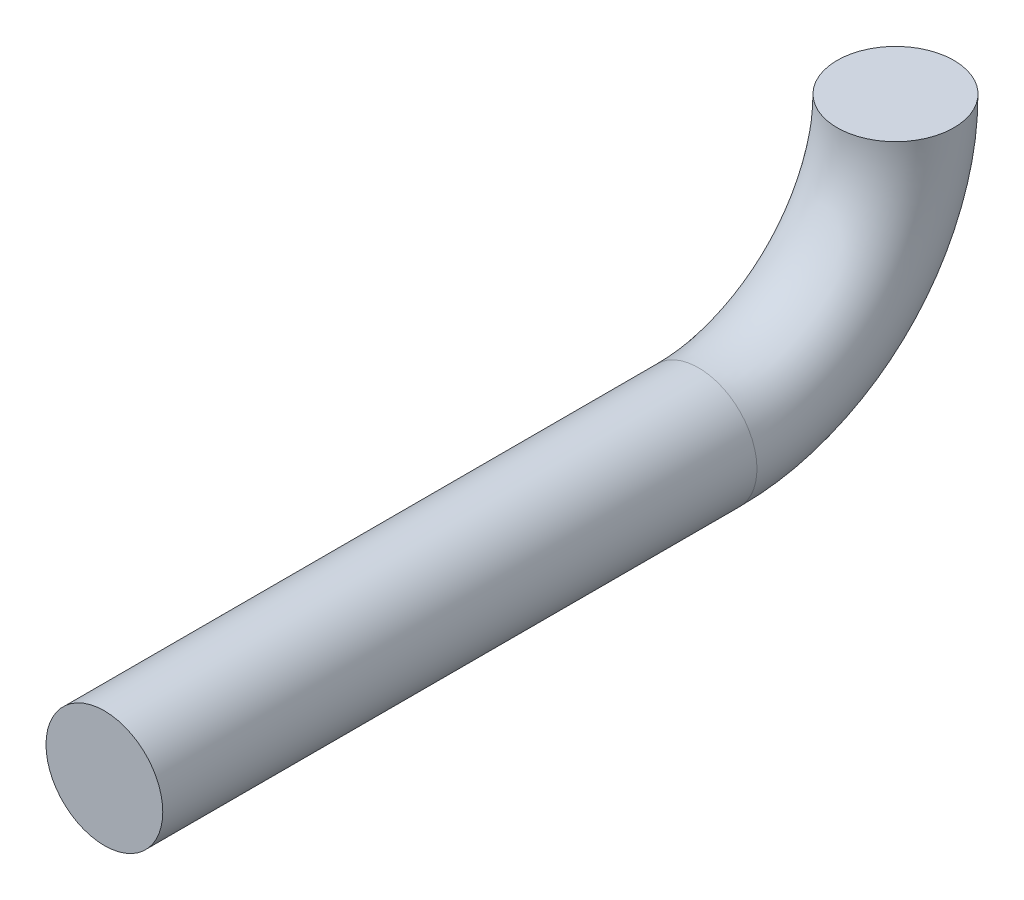
from build123d import *

# Parameters (mm, degrees)
SKETCH2_R = 0.254


with BuildPart() as part:
    # Sweep1: sweep along a path in Sketch1
    with BuildLine(Plane(origin=(0, 0, 0), x_dir=(0, 0, -1), z_dir=(1, 0, 0))) as sweep1_path:
        Line((-2.584985657, -0.856837323), (0, -0.856837323))
        ThreePointArc((0, -0.856837323), (0.605875482, -0.605875482), (0.856837323, 0))
    # Sketch2 → Sweep1 (sweep)
    with BuildSketch(Plane(origin=(0, 0, 0), x_dir=(1, 0, 0), z_dir=(0, 1, 0))):
        with Locations((0, 0.856837323)):
            Circle(SKETCH2_R)
    sweep(path=sweep1_path.line)


solid = part.part
